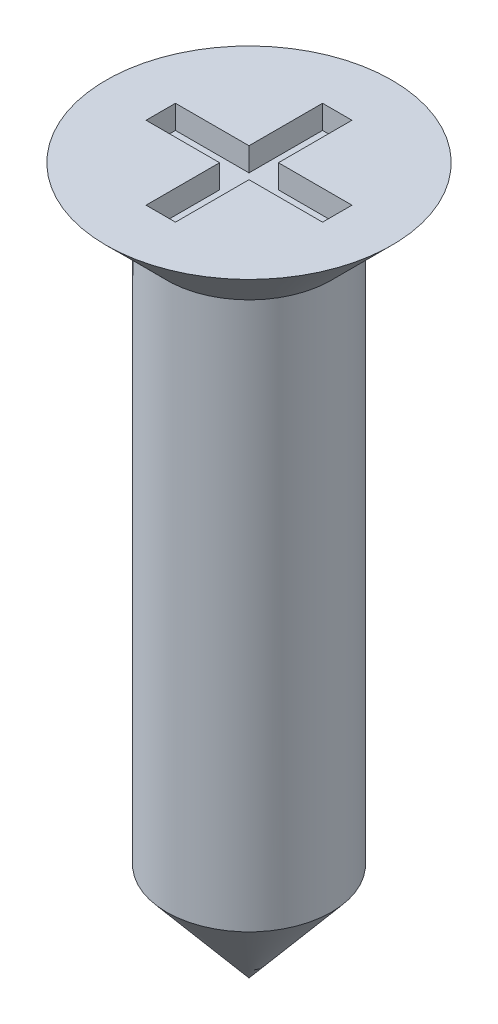
from build123d import *

# Parameters (mm, degrees)
CUT_EXTRUDE1_DEPTH = 0.2


with BuildPart() as part:
    # Sketch1 → Revolve1 (revolve)
    with BuildSketch(Plane.XY):
        Polygon((0, 0), (-1.215, 0), (-0.7, -0.515), (-0.7, -5.165772485), (0, -6), align=None)
    revolve(axis=Axis((0, -6, 0), (0, 1, 0)))

    # Sketch2 → Cut-Extrude1 (cut)
    with BuildSketch(Plane(origin=(0, 0, 0), x_dir=(1, 0, 0), z_dir=(0, 1, 0))):
        Polygon((-0.75, -0.125), (-0.125, -0.125), (-0.125, -0.75), (0.125, -0.75), (0.125, -0.125), (0.75, -0.125), (0.75, 0.125), (0.125, 0.125), (0.125, 0.75), (-0.125, 0.75), (-0.125, 0.125), (-0.75, 0.125), align=None)
    extrude(amount=-CUT_EXTRUDE1_DEPTH, mode=Mode.SUBTRACT)


solid = part.part
